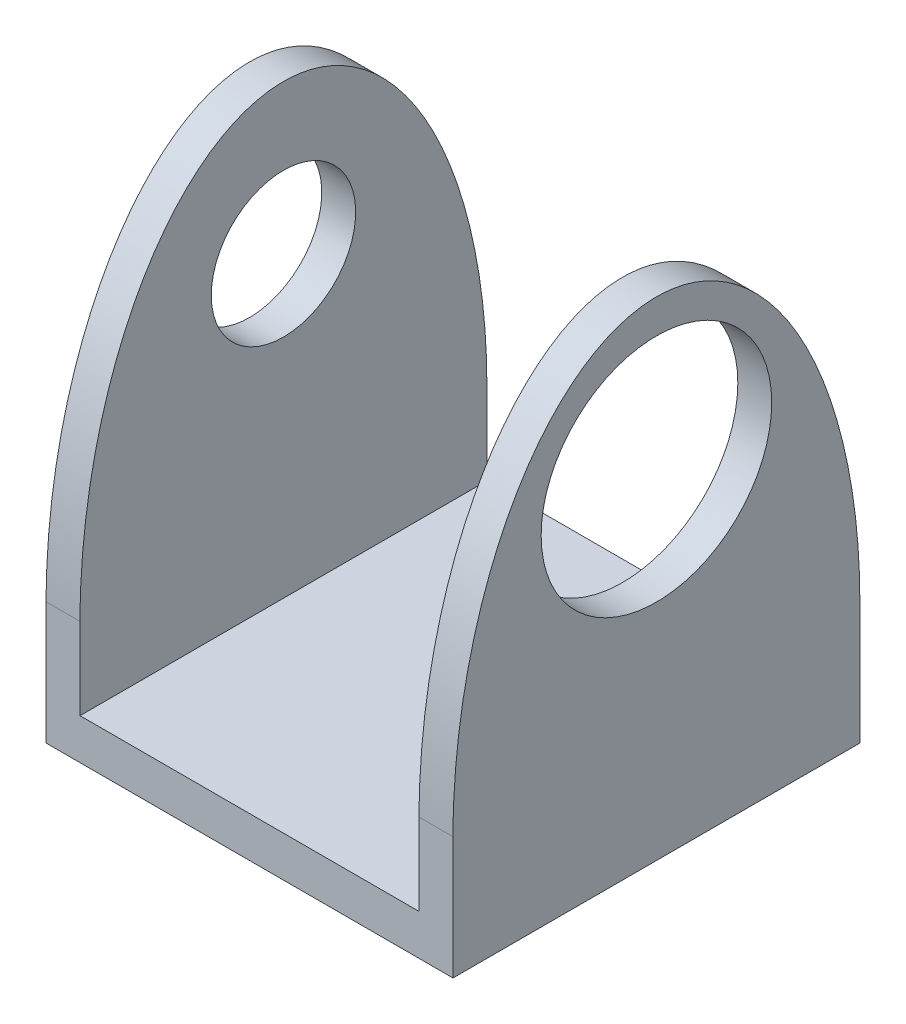
from build123d import *

# Parameters (mm, degrees)
BOSS_EXTRUDE1_DEPTH       = 7.62
F_6_32_TAPPED_HOLE1_D     = 2.7051
F_6_32_TAPPED_HOLE1_DEPTH = 0.635
CUT_EXTRUDE1_REACH        = 9.62
SKETCH6_R                 = 2.159
CUT_EXTRUDE6_DEPTH        = 8.62
SKETCH27_W                = 5.344661664
SKETCH27_H                = 4.789513508
BOSS_EXTRUDE2_DEPTH       = 0.0254


with BuildPart() as part:
    # Sketch1 → Boss-Extrude1 (new body)
    with BuildSketch(Plane.XY):
        Polygon((-3.353873239, 6.85218662), (-3.353873239, -2.29181338), (4.266126761, -2.29181338), (4.266126761, 6.85218662), (3.631126761, 6.85218662), (3.631126761, -1.52981338), (-2.718873239, -1.52981338), (-2.718873239, 6.85218662), align=None)
    extrude(amount=BOSS_EXTRUDE1_DEPTH)

    # #6-32 Tapped Hole1
    with Locations(Plane.ZY.offset(3.353873239)):
        with Locations((3.81, 4.05818662)):
            Hole(F_6_32_TAPPED_HOLE1_D / 2, depth=F_6_32_TAPPED_HOLE1_DEPTH)

    # Sketch6 → Cut-Extrude1 (cut, up to next)
    with BuildSketch(Plane(origin=(4.266126761, 0, 0), x_dir=(0, 0, -1), z_dir=(1, 0, 0)), mode=Mode.PRIVATE) as cut_extrude1_sk1:
        with Locations((-3.81, 4.05818662)):
            Circle(SKETCH6_R)
    cut_extrude1_tool1 = extrude(cut_extrude1_sk1.sketch, amount=-CUT_EXTRUDE1_REACH, mode=Mode.PRIVATE) & part.part
    add(cut_extrude1_tool1.solids().sort_by_distance((4.266127, 4.058187, 3.81))[0], mode=Mode.SUBTRACT)

    # Sketch26 → Cut-Extrude6 (cut, through all)
    with BuildSketch(Plane(origin=(4.266126761, 0, 0), x_dir=(0, 0, -1), z_dir=(1, 0, 0))):
        with BuildLine():
            add(Edge.make_bspline(
                [(0, 0), (0, 6.85218662), (-3.81, 6.85218662)],
                knots=[4.71238898, 4.71238898, 4.71238898, 6.283185307, 6.283185307, 6.283185307], degree=2, weights=[1, 0.707106781, 1]))
            Line((0, 0), (0, 6.85218662))
            Line((0, 6.85218662), (-3.81, 6.85218662))
        make_face()
        with BuildLine():
            add(Edge.make_bspline(
                [(-3.81, 6.85218662), (-7.62, 6.85218662), (-7.62, 0)],
                knots=[6.283185307, 6.283185307, 6.283185307, 7.853981634, 7.853981634, 7.853981634], degree=2, weights=[1, 0.707106781, 1]))
            Line((-3.81, 6.85218662), (-7.62, 6.85218662))
            Line((-7.62, 6.85218662), (-7.62, 0))
        make_face()
    extrude(amount=-CUT_EXTRUDE6_DEPTH, mode=Mode.SUBTRACT)

    # Sketch27 → Boss-Extrude2 (add)
    with BuildSketch(Plane.XZ.offset(2.29181338)):
        with Locations((0.586749856, 3.842655774)):
            Rectangle(SKETCH27_W, SKETCH27_H)
    extrude(amount=BOSS_EXTRUDE2_DEPTH)


solid = part.part
